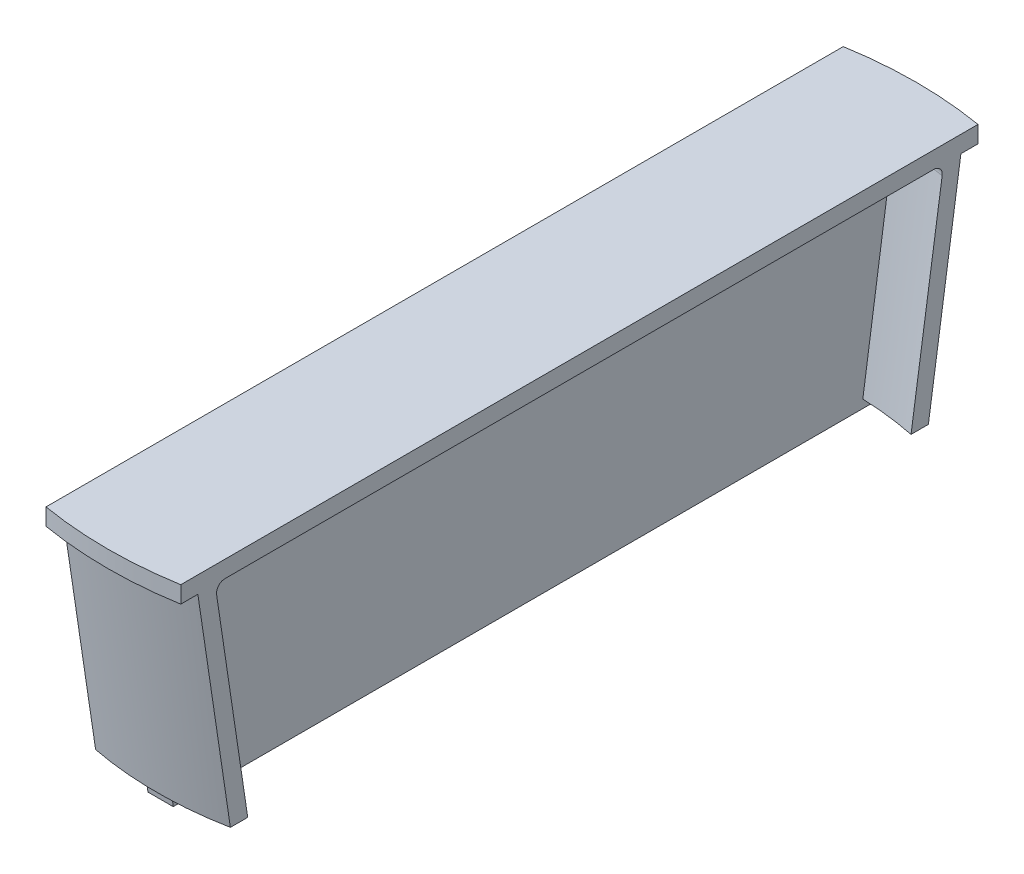
from build123d import *

# Parameters (mm, degrees)
BOSS_EXTRUDE2_DEPTH = 1.5
CUTPLANE1_SKETCH_W  = 123.196195192
CUTPLANE1_SKETCH_H  = 53.525097373
CUT_EXTRUDE6_DEPTH  = 111
CUTPLANE2_SKETCH_W  = 123.196195192
CUTPLANE2_SKETCH_H  = 53.525097373
CUT_EXTRUDE7_DEPTH  = 111


with BuildPart() as part:
    # Sketch1 → Revolve1 (revolve)
    with BuildSketch(Plane.XY, mode=Mode.PRIVATE) as revolve1_sk:
        with BuildLine():
            Line((0, 0), (-48, 0))
            Line((-48, 0), (-48, -2))
            Line((-48, -2), (-46, -2))
            Line((-46, -2), (-42.202855897, -27.901871877))
            Line((-42.202855897, -27.901871877), (-40.181479372, -27.901871877))
            Line((-40.181479372, -27.901871877), (-43.810762695, -3.145046985))
            ThreePointArc((-43.810762695, -3.145046985), (-43.577990749, -2.346183124), (-42.821337927, -2))
            Line((-42.821337927, -2), (0, -2))
            Line((0, -2), (0, 0))
        make_face()
    revolve(revolve1_sk.sketch.rotate(Axis((0, 0, 0), (0, -1, 0)), 270), axis=Axis((0, 0, 0), (0, -1, 0)))

    # Sketch13 → Boss-Extrude2 (add, symmetric)
    with BuildSketch(Plane(origin=(0, 0, 0), x_dir=(0, 0, -1), z_dir=(1, 0, 0))):
        Polygon((-45.341508105, -0.931589376), (45.341508105, -0.931589376), (41.320088317, -28.8804569), (-41.722230296, -28.8804569), align=None)
    extrude(amount=BOSS_EXTRUDE2_DEPTH, both=True)

    # CutPlane1 Sketch → Cut-Extrude6 (cut)
    with BuildSketch(Plane(origin=(8, 0, 0), x_dir=(0, 0, -1), z_dir=(1, 0, 0))):
        with Locations((0.221178088, -12.173153045)):
            Rectangle(CUTPLANE1_SKETCH_W, CUTPLANE1_SKETCH_H)
    extrude(amount=CUT_EXTRUDE6_DEPTH, mode=Mode.SUBTRACT)

    # CutPlane2 Sketch → Cut-Extrude7 (cut)
    with BuildSketch(Plane(origin=(-8, 0, 0), x_dir=(0, 0, -1), z_dir=(1, 0, 0))):
        with Locations((0.221178088, -12.173153045)):
            Rectangle(CUTPLANE2_SKETCH_W, CUTPLANE2_SKETCH_H)
    extrude(amount=-CUT_EXTRUDE7_DEPTH, mode=Mode.SUBTRACT)


solid = part.part
